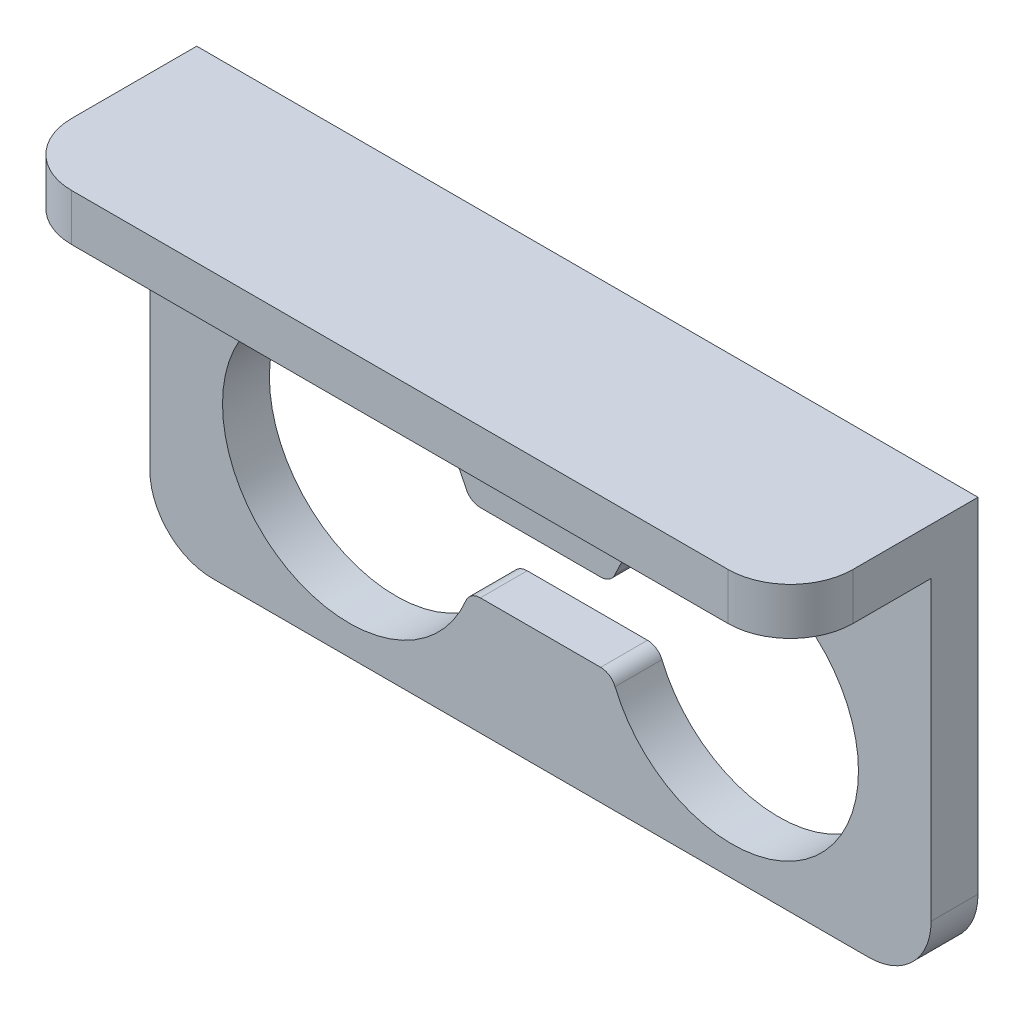
from build123d import *

# Parameters (mm, degrees)
SKETCH_1_W          = 50
SKETCH_1_H          = 20
EXTRUDE_1_DEPTH     = 3
SKETCH_2_W          = 50
SKETCH_2_H          = 12
EXTRUDE_2_DEPTH     = 6
SKETCH_5_W          = 50
SKETCH_5_H          = 9
CUT_EXTRUDE_2_DEPTH = 3
FILLET_1_R          = 4


with BuildPart() as part:
    # 草图1 → 凸台-拉伸1 (new body)
    with BuildSketch(Plane.XY):
        Rectangle(SKETCH_1_W, SKETCH_1_H)
        with BuildLine():
            Line((-3.85, 2.5), (3.85, 2.5))
            ThreePointArc((3.85, 2.5), (4.404700196, 2.667949706), (4.773076923, 3.115384615))
            ThreePointArc((4.773076923, 3.115384615), (20.35, 0), (4.773076923, -3.115384615))
            ThreePointArc((4.773076923, -3.115384615), (4.404700196, -2.667949706), (3.85, -2.5))
            Line((3.85, -2.5), (-3.85, -2.5))
            ThreePointArc((-3.85, -2.5), (-4.404700196, -2.667949706), (-4.773076923, -3.115384615))
            ThreePointArc((-4.773076923, -3.115384615), (-20.35, 0), (-4.773076923, 3.115384615))
            ThreePointArc((-4.773076923, 3.115384615), (-4.404700196, 2.667949706), (-3.85, 2.5))
        make_face(mode=Mode.SUBTRACT)
        with BuildLine():
            Line((3.25, 5.5), (-3.25, 5.5))
            ThreePointArc((-3.25, 5.5), (-5, 7.25), (-3.25, 9))
            Line((-3.25, 9), (3.25, 9))
            ThreePointArc((3.25, 9), (5, 7.25), (3.25, 5.5))
        make_face(mode=Mode.SUBTRACT)
    extrude(amount=EXTRUDE_1_DEPTH)

    # 草图2 → 凸台-拉伸2 (add)
    with BuildSketch(Plane(origin=(0, 10, 0), x_dir=(1, 0, 0), z_dir=(0, 1, 0))):
        with Locations((0, -6)):
            Rectangle(SKETCH_2_W, SKETCH_2_H)
    extrude(amount=EXTRUDE_2_DEPTH)

    # 草图5 → 切除-拉伸2 (cut)
    with BuildSketch(Plane.XZ.offset(-10)):
        with Locations((0, 7.5)):
            Rectangle(SKETCH_5_W, SKETCH_5_H)
    extrude(amount=-CUT_EXTRUDE_2_DEPTH, mode=Mode.SUBTRACT)

    # 圆角1
    fillet_1_edges = [part.edges().sort_by_distance(p)[0] for p in [
        (-25, 14.5, 12),
        (25, 14.5, 12),
        (25, -10, 1.5),
        (-25, -10, 1.5),
    ]]
    fillet(fillet_1_edges, radius=FILLET_1_R)


solid = part.part
